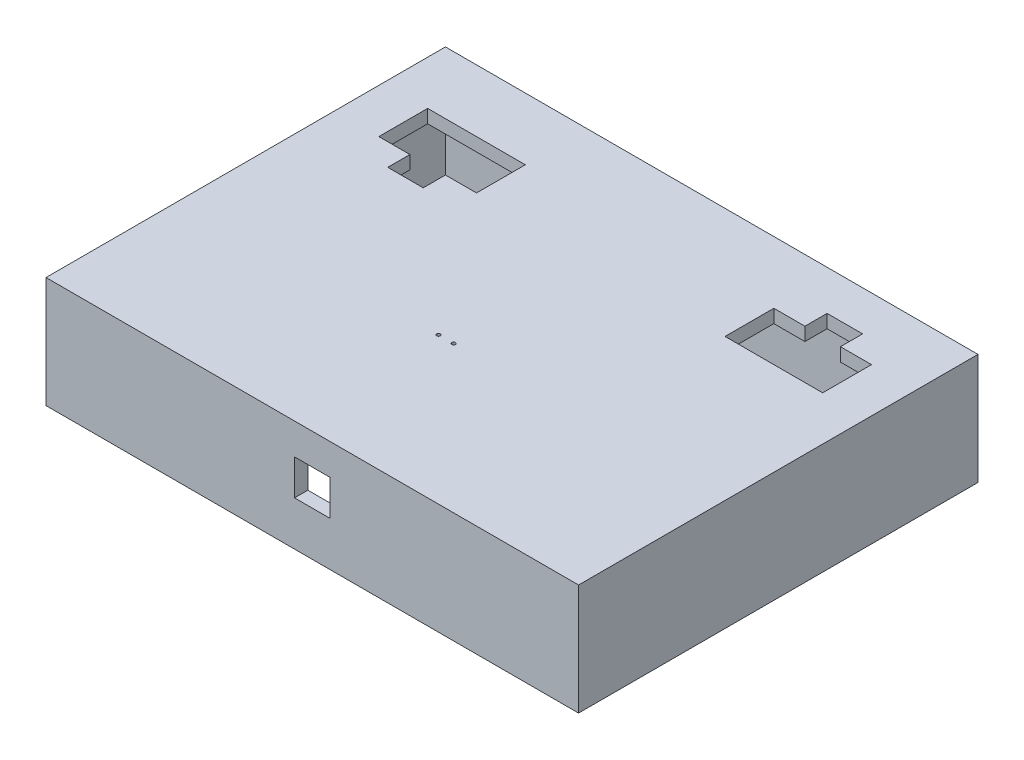
from build123d import *

# Parameters (mm, degrees)
SKETCH1_W           = 120
SKETCH1_H           = 90
BOSS_EXTRUDE1_DEPTH = 25
SKETCH2_W           = 114
SKETCH2_H           = 84
CUT_EXTRUDE1_DEPTH  = 22
SKETCH3_W           = 117
SKETCH3_H           = 87
CUT_EXTRUDE2_DEPTH  = 1.5
CUT_EXTRUDE3_DEPTH  = 11.5
SKETCH5_W           = 8
SKETCH5_H           = 8
CUT_EXTRUDE4_DEPTH  = 11.5
SKETCH6_R           = 0.4
CUT_EXTRUDE6_DEPTH  = 21.5


with BuildPart() as part:
    # Sketch1 → Boss-Extrude1 (new body)
    with BuildSketch(Plane(origin=(0, 0, 0), x_dir=(1, 0, 0), z_dir=(0, 1, 0))):
        Rectangle(SKETCH1_W, SKETCH1_H)
    extrude(amount=BOSS_EXTRUDE1_DEPTH)

    # Sketch2 → Cut-Extrude1 (cut)
    with BuildSketch(Plane.XZ):
        Rectangle(SKETCH2_W, SKETCH2_H)
    extrude(amount=-CUT_EXTRUDE1_DEPTH, mode=Mode.SUBTRACT)

    # Sketch3 → Cut-Extrude2 (cut)
    with BuildSketch(Plane.XZ):
        Rectangle(SKETCH3_W, SKETCH3_H)
    extrude(amount=-CUT_EXTRUDE2_DEPTH, mode=Mode.SUBTRACT)

    # Sketch4 → Cut-Extrude3 (cut)
    with BuildSketch(Plane(origin=(0, 25, 0), x_dir=(1, 0, 0), z_dir=(0, 1, 0))):
        Polygon((28, 31), (35, 31), (35, 36), (43, 36), (43, 31), (50, 31), (50, 20), (28, 20), align=None)
        Polygon((-50, 31), (-50, 20), (-43, 20), (-43, 15), (-35, 15), (-35, 20), (-28, 20), (-28, 31), align=None)
    extrude(amount=-CUT_EXTRUDE3_DEPTH, mode=Mode.SUBTRACT)

    # Sketch5 → Cut-Extrude4 (cut)
    with BuildSketch(Plane.XY.offset(45)):
        with Locations((0, 14)):
            Rectangle(SKETCH5_W, SKETCH5_H)
    extrude(amount=-CUT_EXTRUDE4_DEPTH, mode=Mode.SUBTRACT)

    # Sketch6 → Cut-Extrude6 (cut)
    with BuildSketch(Plane(origin=(0, 25, 0), x_dir=(1, 0, 0), z_dir=(0, 1, 0))):
        with Locations((-4.59237925, -11.959320964)):
            Circle(SKETCH6_R)
        with Locations((-1.19237925, -11.959320964)):
            Circle(SKETCH6_R)
    extrude(amount=-CUT_EXTRUDE6_DEPTH, mode=Mode.SUBTRACT)


solid = part.part
